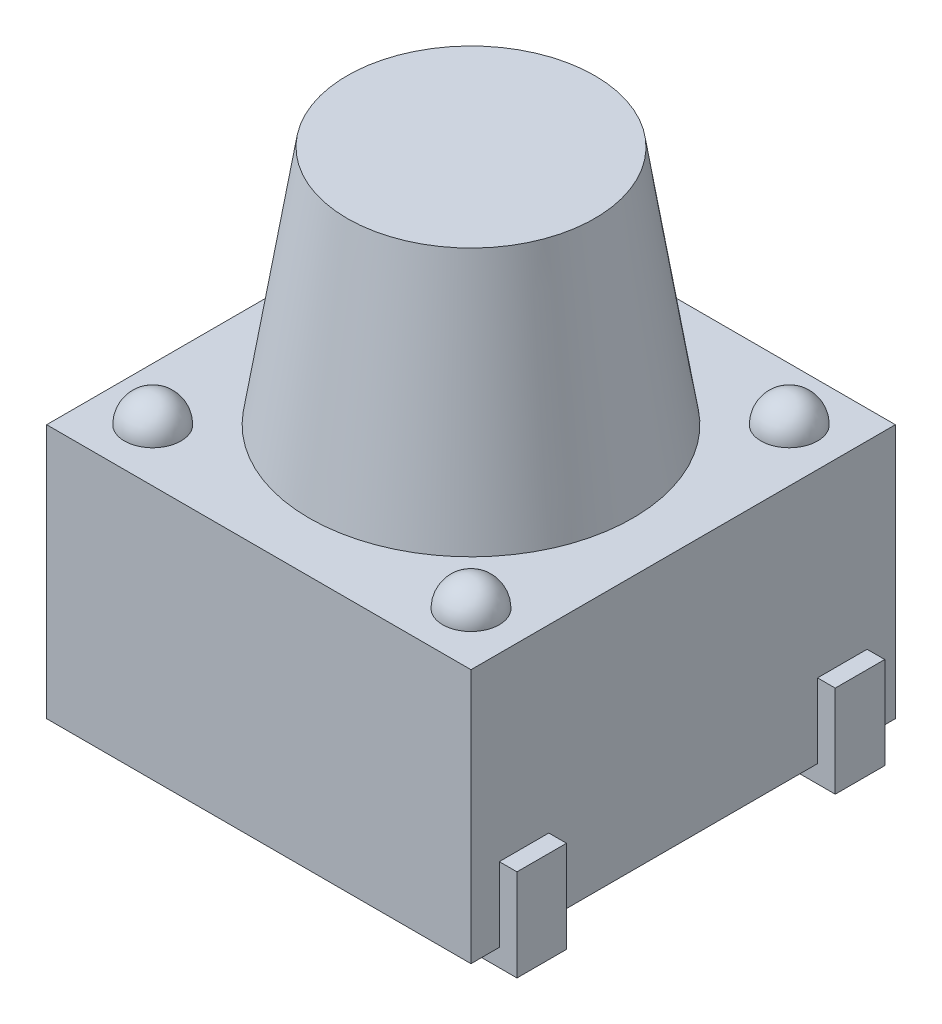
from build123d import *

# Parameters (mm, degrees)
SKETCH1_W            = 6
SKETCH1_H            = 6
EXTRUDE1_DEPTH       = 3.6
EXTRUDE2_DEPTH       = 0.35
MIRROR4_COPY_1_DEPTH = 0.35


with BuildPart() as part:
    # Sketch1 → Extrude1 (new body)
    with BuildSketch(Plane(origin=(0, 0, 0), x_dir=(1, 0, 0), z_dir=(0, 1, 0))):
        Rectangle(SKETCH1_W, SKETCH1_H)
    extrude(amount=EXTRUDE1_DEPTH)

    # Sketch2 → Revolve1 (revolve)
    with BuildSketch(Plane.XY.offset(2.25)):
        with BuildLine():
            Line((-2.25, 3.6), (-1.85, 3.6))
            ThreePointArc((-1.85, 3.6), (-1.967157288, 3.882842712), (-2.25, 4))
            Line((-2.25, 4), (-2.25, 3.6))
        make_face()
    revolve1 = revolve(axis=Axis((-2.25, 4.707394025, 2.25), (0, -1, 0)))

    # Mirror1: Revolve1 across plane
    add(revolve1.mirror(Plane.XY))

    # Mirror2: Revolve1 across plane
    add(revolve1.mirror(Plane(origin=(0, 0, 0), x_dir=(0, 0, 1), z_dir=(1, 0, 0))))

    # Mirror2 copy 1 sketch → Mirror2 copy 1 (revolve)
    with BuildSketch(Plane(origin=(0, 0, -2.25), x_dir=(-1, 0, 0), z_dir=(0, 0, -1))):
        with BuildLine():
            Line((-2.25, 3.6), (-1.85, 3.6))
            ThreePointArc((-1.85, 3.6), (-1.967157288, 3.882842712), (-2.25, 4))
            Line((-2.25, 4), (-2.25, 3.6))
        make_face()
    revolve(axis=Axis((2.25, 4.707394025, -2.25), (0, -1, 0)))

    # Sketch3 → Revolve2 (revolve)
    with BuildSketch(Plane.XY, mode=Mode.PRIVATE) as revolve2_sk:
        Polygon((-2.288507097, 3.6), (-1.75, 7), (0, 7), (0, 3.6), align=None)
    revolve(revolve2_sk.sketch.rotate(Axis((0, 7, 0), (0, -1, 0)), 270), axis=Axis((0, 7, 0), (0, -1, 0)))  # turned: the seam where the file's is

    # Sketch5 → Extrude2 (add, symmetric)
    with BuildSketch(Plane.XY.offset(2.25)):
        Polygon((-3, 1.05), (-3.25, 1.05), (-3.25, -0.25), (-2.215388365, -0.25), (-2.215388365, 0), (-3, 0), align=None)
    extrude2 = extrude(amount=EXTRUDE2_DEPTH, both=True)

    # Mirror3: Extrude2 across plane
    add(extrude2.mirror(Plane.XY))

    # Mirror4: Extrude2 across plane
    add(extrude2.mirror(Plane(origin=(0, 0, 0), x_dir=(0, 0, 1), z_dir=(1, 0, 0))))

    # Mirror4 copy 1 sketch → Mirror4 copy 1 (add, symmetric)
    with BuildSketch(Plane(origin=(0, 0, -2.25), x_dir=(-1, 0, 0), z_dir=(0, 0, -1))):
        Polygon((-3, 1.05), (-3.25, 1.05), (-3.25, -0.25), (-2.215388365, -0.25), (-2.215388365, 0), (-3, 0), align=None)
    extrude(amount=MIRROR4_COPY_1_DEPTH, both=True)


solid = part.part
